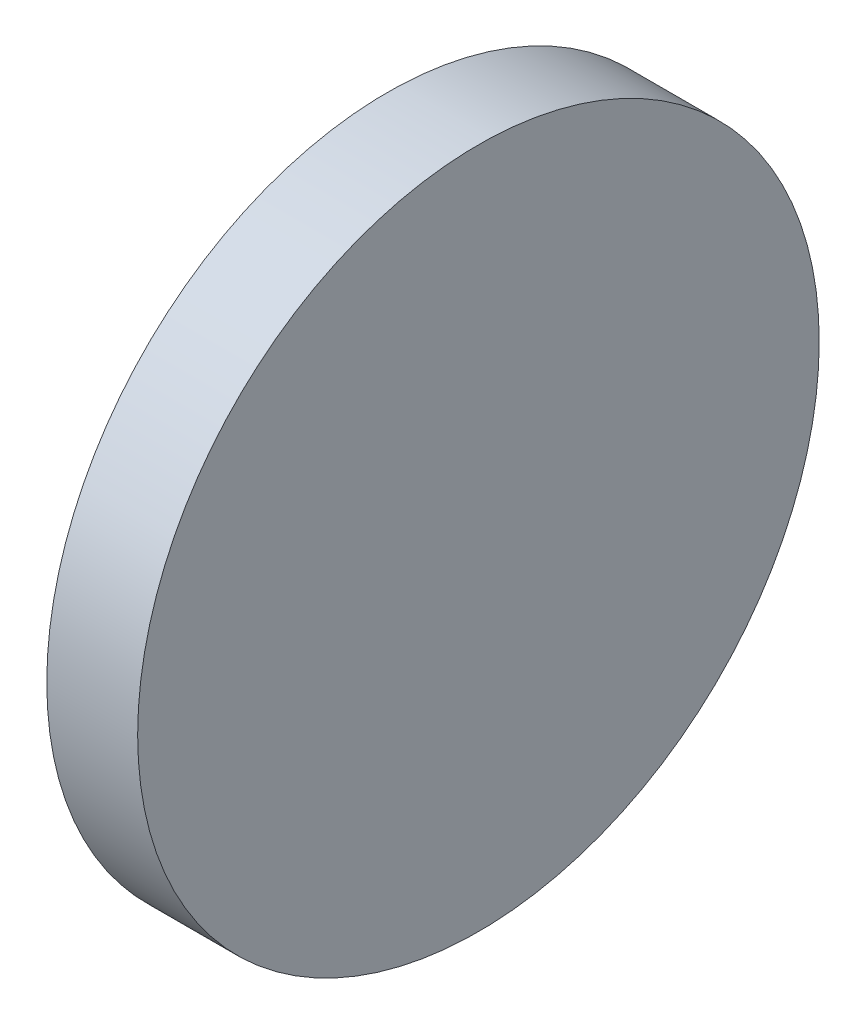
from build123d import *

# Parameters (mm, degrees)
SKETCH_1_W = 2
SKETCH_1_H = 7.5


with BuildPart() as part:
    # 草图1 → 旋转1 (revolve)
    with BuildSketch(Plane.XY, mode=Mode.PRIVATE) as revolve_1_sk:
        with Locations((131.06399853, 42.396589675)):
            Rectangle(SKETCH_1_W, SKETCH_1_H)
    revolve(revolve_1_sk.sketch.rotate(Axis((127.000400996, 38.646589675, 0), (1, 0, 0)), 90), axis=Axis((127.000400996, 38.646589675, 0), (1, 0, 0)))  # turned: the seam where the file's is


solid = part.part
